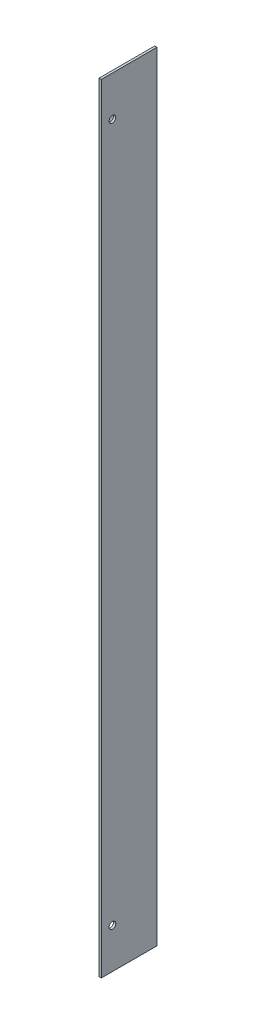
from build123d import *

# Parameters (mm, degrees)
CROQUIS2_W              = 1
CROQUIS2_H              = 350
SALIENTE_EXTRUIR2_DEPTH = 25
CROQUIS5_R              = 1.5
CORTAR_EXTRUIR2_DEPTH   = 1
CROQUIS1_R              = 1.5
SALIENTE_EXTRUIR3_DEPTH = 1


with BuildPart() as part:
    # Croquis2 → Saliente-Extruir2 (new body)
    with BuildSketch(Plane.XY):
        with Locations((-54.941785307, -113.819624774)):
            Rectangle(CROQUIS2_W, CROQUIS2_H)
    extrude(amount=SALIENTE_EXTRUIR2_DEPTH)

    # Croquis5 → Cortar-Extruir2 (cut)
    with BuildSketch(Plane(origin=(-54.441785307, 0, 0), x_dir=(0, 0, -1), z_dir=(1, 0, 0))):
        with Locations((-20, 43.180375226)):
            Circle(CROQUIS5_R)
        with Locations((-20, -270.819624774)):
            Circle(CROQUIS5_R)
    extrude(amount=-CORTAR_EXTRUIR2_DEPTH, mode=Mode.SUBTRACT)

    # Croquis1 → Saliente-Extruir3 (add)
    with BuildSketch(Plane.XY):
        Polygon((-55.441785307, 61.180375226), (-79.441785307, 37.180375226), (-79.441785307, -264.819624774), (-55.441785307, -288.819624774), align=None)
        with Locations((-74.441785307, 1.180375226)):
            Circle(CROQUIS1_R, mode=Mode.SUBTRACT)
        with Locations((-74.441785307, -228.819624774)):
            Circle(CROQUIS1_R, mode=Mode.SUBTRACT)
    extrude(amount=SALIENTE_EXTRUIR3_DEPTH)


solid = part.part
